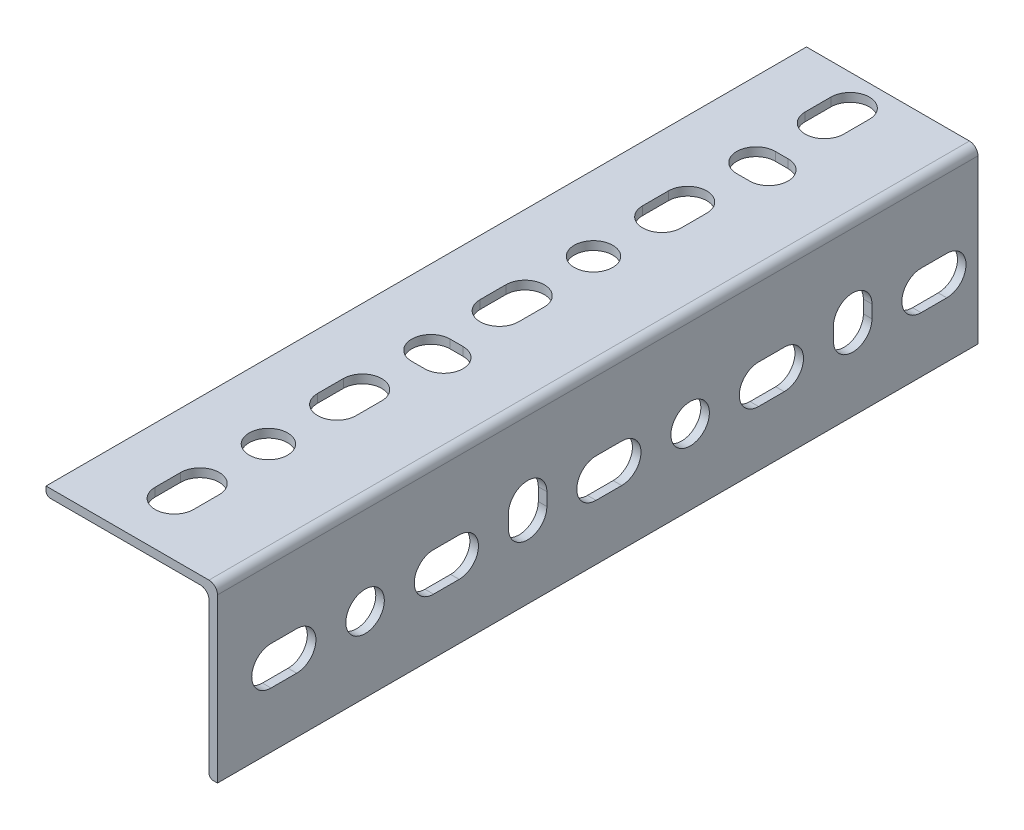
from build123d import *

# Parameters (mm, degrees)
STRUCTURAL_MEMBER1_DEPTH        = 177.8
SLOT_DEPTH                      = 187.62491795
SKETCH4_R                       = 4.5
HOLE_DEPTH                      = 187.62491795
VERT_SLOT_DEPTH                 = 187.62491795
SLOT_PATTERN_COUNT              = 5
SLOT_PATTERN_PITCH              = 38
HOLE_PATTERN_COUNT              = 2
HOLE_PATTERN_PITCH              = 76
LPATTERN1_COUNT                 = 2
LPATTERN1_PITCH                 = 76
OTHER_SIDE_CUTS_COUNT           = 2
OTHER_SIDE_CUTS_ANGLE           = 90
OTHER_SIDE_CUTS_COPY_1_DEPTH    = 187.62491795
OTHER_SIDE_CUTS_COPY_2_DEPTH    = 187.62491795
OTHER_SIDE_CUTS_COPY_3_DEPTH    = 187.62491795
OTHER_SIDE_CUTS_COPY_4_DEPTH    = 187.62491795
OTHER_SIDE_CUTS_COPY_5_SKETCH_R = 4.5
OTHER_SIDE_CUTS_COPY_5_DEPTH    = 187.62491795
OTHER_SIDE_CUTS_COPY_6_DEPTH    = 187.62491795


with BuildPart() as part:
    # Sketch13 → Structural Member1 (new body)
    with BuildSketch(Plane(origin=(0, 0, 0), x_dir=(-1, 0, 0), z_dir=(0, 0, -1))):
        with BuildLine():
            Line((40.1, 0), (2, 0))
            ThreePointArc((2, 0), (0.585786438, -0.585786438), (0, -2))
            Line((0, -2), (0, -40.1))
            Line((0, -40.1), (1, -40.1))
            ThreePointArc((1, -40.1), (1.707106781, -39.807106781), (2, -39.1))
            Line((2, -39.1), (2, -4))
            ThreePointArc((2, -4), (2.585786438, -2.585786438), (4, -2))
            Line((4, -2), (39.1, -2))
            ThreePointArc((39.1, -2), (39.807106781, -1.707106781), (40.1, -1))
            Line((40.1, -1), (40.1, 0))
        make_face()
    extrude(amount=STRUCTURAL_MEMBER1_DEPTH)

    # Sketch3 → Slot (cut, through all)
    with BuildSketch(Plane(origin=(0, 0, 0), x_dir=(1, 0, 0), z_dir=(0, 1, 0))):
        with BuildLine():
            Line((-27.1, 12.5), (-27.1, 18.5))
            ThreePointArc((-27.1, 18.5), (-22.6, 23), (-18.1, 18.5))
            Line((-18.1, 18.5), (-18.1, 12.5))
            ThreePointArc((-18.1, 12.5), (-22.6, 8), (-27.1, 12.5))
        make_face()
    slot = extrude(amount=-SLOT_DEPTH, mode=Mode.SUBTRACT)

    # Sketch4 → Hole (cut, through all)
    with BuildSketch(Plane(origin=(0, 0, 0), x_dir=(1, 0, 0), z_dir=(0, 1, 0))):
        with Locations(Location((-22.6, 34.5, 0), (0, 0, 180))):
            Circle(SKETCH4_R)
    hole = extrude(amount=-HOLE_DEPTH, mode=Mode.SUBTRACT)

    # Sketch14 → Vert Slot (cut, through all)
    with BuildSketch(Plane(origin=(0, 0, 0), x_dir=(1, 0, 0), z_dir=(0, 1, 0))):
        with BuildLine():
            Line((-19.6, 68), (-22.6, 68))
            ThreePointArc((-22.6, 68), (-27.1, 72.5), (-22.6, 77))
            Line((-22.6, 77), (-19.6, 77))
            ThreePointArc((-19.6, 77), (-15.1, 72.5), (-19.6, 68))
        make_face()
    vert_slot = extrude(amount=-VERT_SLOT_DEPTH, mode=Mode.SUBTRACT)

    # Slot Pattern: Slot ×5
    with Locations(*[(0, 0, -i * SLOT_PATTERN_PITCH) for i in range(1, SLOT_PATTERN_COUNT)]):
        add(slot, mode=Mode.SUBTRACT)

    # Hole Pattern: Hole ×2
    with Locations(*[(0, 0, -i * HOLE_PATTERN_PITCH) for i in range(1, HOLE_PATTERN_COUNT)]):
        add(hole, mode=Mode.SUBTRACT)

    # LPattern1: Vert Slot ×2
    with Locations(*[(0, 0, -i * LPATTERN1_PITCH) for i in range(1, LPATTERN1_COUNT)]):
        add(vert_slot, mode=Mode.SUBTRACT)

    # Other side cuts: Slot, Hole, Vert Slot ×2 about axis
    other_side_cuts_axis = Axis((-4, -4, 0), (0, 0, 1))
    add([slot.rotate(other_side_cuts_axis, i * OTHER_SIDE_CUTS_ANGLE / (OTHER_SIDE_CUTS_COUNT - 1)) for i in range(1, OTHER_SIDE_CUTS_COUNT)], mode=Mode.SUBTRACT)
    add([hole.rotate(other_side_cuts_axis, i * OTHER_SIDE_CUTS_ANGLE / (OTHER_SIDE_CUTS_COUNT - 1)) for i in range(1, OTHER_SIDE_CUTS_COUNT)], mode=Mode.SUBTRACT)
    add([vert_slot.rotate(other_side_cuts_axis, i * OTHER_SIDE_CUTS_ANGLE / (OTHER_SIDE_CUTS_COUNT - 1)) for i in range(1, OTHER_SIDE_CUTS_COUNT)], mode=Mode.SUBTRACT)

    # Other side cuts copy 1 sketch → Other side cuts copy 1 (cut, through all)
    with BuildSketch(Plane(origin=(-8, 0, -38), x_dir=(0, 1, 0), z_dir=(-1, 0, 0))):
        with BuildLine():
            Line((-27.1, 12.5), (-27.1, 18.5))
            ThreePointArc((-27.1, 18.5), (-22.6, 23), (-18.1, 18.5))
            Line((-18.1, 18.5), (-18.1, 12.5))
            ThreePointArc((-18.1, 12.5), (-22.6, 8), (-27.1, 12.5))
        make_face()
    extrude(amount=-OTHER_SIDE_CUTS_COPY_1_DEPTH, mode=Mode.SUBTRACT)

    # Other side cuts copy 2 sketch → Other side cuts copy 2 (cut, through all)
    with BuildSketch(Plane(origin=(-8, 0, -76), x_dir=(0, 1, 0), z_dir=(-1, 0, 0))):
        with BuildLine():
            Line((-27.1, 12.5), (-27.1, 18.5))
            ThreePointArc((-27.1, 18.5), (-22.6, 23), (-18.1, 18.5))
            Line((-18.1, 18.5), (-18.1, 12.5))
            ThreePointArc((-18.1, 12.5), (-22.6, 8), (-27.1, 12.5))
        make_face()
    extrude(amount=-OTHER_SIDE_CUTS_COPY_2_DEPTH, mode=Mode.SUBTRACT)

    # Other side cuts copy 3 sketch → Other side cuts copy 3 (cut, through all)
    with BuildSketch(Plane(origin=(-8, 0, -114), x_dir=(0, 1, 0), z_dir=(-1, 0, 0))):
        with BuildLine():
            Line((-27.1, 12.5), (-27.1, 18.5))
            ThreePointArc((-27.1, 18.5), (-22.6, 23), (-18.1, 18.5))
            Line((-18.1, 18.5), (-18.1, 12.5))
            ThreePointArc((-18.1, 12.5), (-22.6, 8), (-27.1, 12.5))
        make_face()
    extrude(amount=-OTHER_SIDE_CUTS_COPY_3_DEPTH, mode=Mode.SUBTRACT)

    # Other side cuts copy 4 sketch → Other side cuts copy 4 (cut, through all)
    with BuildSketch(Plane(origin=(-8, 0, -152), x_dir=(0, 1, 0), z_dir=(-1, 0, 0))):
        with BuildLine():
            Line((-27.1, 12.5), (-27.1, 18.5))
            ThreePointArc((-27.1, 18.5), (-22.6, 23), (-18.1, 18.5))
            Line((-18.1, 18.5), (-18.1, 12.5))
            ThreePointArc((-18.1, 12.5), (-22.6, 8), (-27.1, 12.5))
        make_face()
    extrude(amount=-OTHER_SIDE_CUTS_COPY_4_DEPTH, mode=Mode.SUBTRACT)

    # Other side cuts copy 5 sketch → Other side cuts copy 5 (cut, through all)
    with BuildSketch(Plane(origin=(-8, 0, -76), x_dir=(0, 1, 0), z_dir=(-1, 0, 0))):
        with Locations(Location((-22.6, 34.5, 0), (0, 0, 180))):
            Circle(OTHER_SIDE_CUTS_COPY_5_SKETCH_R)
    extrude(amount=-OTHER_SIDE_CUTS_COPY_5_DEPTH, mode=Mode.SUBTRACT)

    # Other side cuts copy 6 sketch → Other side cuts copy 6 (cut, through all)
    with BuildSketch(Plane(origin=(-8, 0, -76), x_dir=(0, 1, 0), z_dir=(-1, 0, 0))):
        with BuildLine():
            Line((-19.6, 68), (-22.6, 68))
            ThreePointArc((-22.6, 68), (-27.1, 72.5), (-22.6, 77))
            Line((-22.6, 77), (-19.6, 77))
            ThreePointArc((-19.6, 77), (-15.1, 72.5), (-19.6, 68))
        make_face()
    extrude(amount=-OTHER_SIDE_CUTS_COPY_6_DEPTH, mode=Mode.SUBTRACT)


solid = part.part
